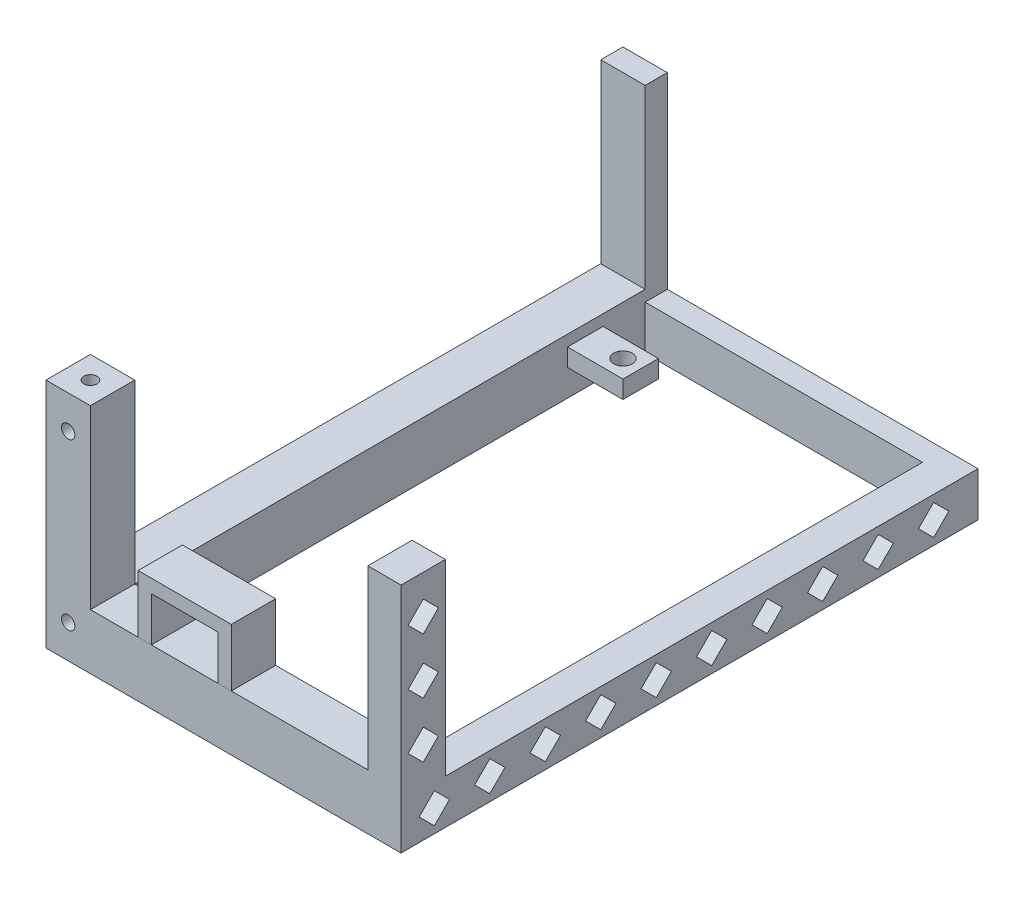
from build123d import *

# Parameters (mm, degrees)
SKETCH1_W           = 80
SKETCH1_H           = 130
BOSS_EXTRUDE1_DEPTH = 10
BOSS_EXTRUDE2_DEPTH = 42.3
CUT_EXTRUDE1_DEPTH  = 5.25
SKETCH4_R           = 2.1
CUT_EXTRUDE2_DEPTH  = 11
CUT_EXTRUDE3_DEPTH  = 11
SKETCH7_W           = 115
SKETCH7_H           = 39.8
CUT_EXTRUDE4_DEPTH  = 11
SKETCH8_W           = 62.5
SKETCH8_H           = 39.8
CUT_EXTRUDE5_DEPTH  = 10
SKETCH9_R           = 1.5
CUT_EXTRUDE6_DEPTH  = 4
SKETCH10_R          = 1.5
CUT_EXTRUDE7_DEPTH  = 4
SKETCH11_W          = 12.5
SKETCH11_H          = 8
CUT_EXTRUDE8_DEPTH  = 6
BOSS_EXTRUDE3_DEPTH = 10
SKETCH14_R          = 1.5
CUT_EXTRUDE9_DEPTH  = 4


with BuildPart() as part:
    # Sketch1 → Boss-Extrude1 (new body)
    with BuildSketch(Plane(origin=(0, 0, 0), x_dir=(1, 0, 0), z_dir=(0, 1, 0))):
        with Locations((-5, 0)):
            Rectangle(SKETCH1_W, SKETCH1_H)
    extrude(amount=BOSS_EXTRUDE1_DEPTH)

    # Sketch2 → Boss-Extrude2 (add)
    with BuildSketch(Plane(origin=(0, 10, 0), x_dir=(1, 0, 0), z_dir=(0, 1, 0))):
        Polygon((35, -65), (-45, -65), (-45, 65), (-35, 65), (-35, -55), (35, -55), align=None)
    extrude(amount=BOSS_EXTRUDE2_DEPTH)

    # Sketch3 → Cut-Extrude1 (cut)
    with BuildSketch(Plane(origin=(35, 0, 0), x_dir=(0, 0, -1), z_dir=(1, 0, 0))):
        Polygon((20.925, 5), (17.5, 8.425), (14.075, 5), (17.5, 1.575), align=None)
        Polygon((33.425, 5), (30, 8.425), (26.575, 5), (30, 1.575), align=None)
        Polygon((5, 8.425), (1.575, 5), (5, 1.575), (8.425, 5), align=None)
        Polygon((-4.075, 5), (-7.5, 8.425), (-10.925, 5), (-7.5, 1.575), align=None)
        Polygon((-16.575, 5), (-20, 8.425), (-23.425, 5), (-20, 1.575), align=None)
        Polygon((-29.075, 5), (-32.5, 8.425), (-35.925, 5), (-32.5, 1.575), align=None)
        Polygon((-41.575, 5), (-45, 8.425), (-48.425, 5), (-45, 1.575), align=None)
        Polygon((-54.075, 5), (-57.5, 8.425), (-60.925, 5), (-57.5, 1.575), align=None)
        Polygon((-63.425, 31.15), (-60, 34.575), (-56.575, 31.15), (-60, 27.725), align=None)
        Polygon((-60, 40.225), (-63.425, 43.65), (-60, 47.075), (-56.575, 43.65), align=None)
        Polygon((-60, 15.225), (-63.425, 18.65), (-60, 22.075), (-56.575, 18.65), align=None)
        Polygon((45.925, 5), (42.5, 8.425), (39.075, 5), (42.5, 1.575), align=None)
        Polygon((58.425, 5), (55, 8.425), (51.575, 5), (55, 1.575), align=None)
    extrude(amount=-CUT_EXTRUDE1_DEPTH, mode=Mode.SUBTRACT)

    # Sketch4 → Cut-Extrude2 (cut, through all)
    with BuildSketch(Plane(origin=(0, 10, 0), x_dir=(1, 0, 0), z_dir=(0, 1, 0))):
        with Locations((-26.5, 46.5)):
            Circle(SKETCH4_R)
    extrude(amount=-CUT_EXTRUDE2_DEPTH, mode=Mode.SUBTRACT)

    # Sketch5 → Cut-Extrude3 (cut, through all)
    with BuildSketch(Plane(origin=(0, 10, 0), x_dir=(1, 0, 0), z_dir=(0, 1, 0))):
        Polygon((-35, -55), (-35, 42.5), (-22.5, 42.5), (-22.5, 50.5), (-35, 50.5), (-35, 60), (27.5, 60), (27.5, -55), align=None)
    extrude(amount=-CUT_EXTRUDE3_DEPTH, mode=Mode.SUBTRACT)

    # Sketch7 → Cut-Extrude4 (cut, through all)
    with BuildSketch(Plane(origin=(-35, 0, 0), x_dir=(0, 0, -1), z_dir=(1, 0, 0))):
        with Locations((2.5, 32.4)):
            Rectangle(SKETCH7_W, SKETCH7_H)
    extrude(amount=-CUT_EXTRUDE4_DEPTH, mode=Mode.SUBTRACT)

    # Sketch8 → Cut-Extrude5 (cut)
    with BuildSketch(Plane(origin=(0, 0, 55), x_dir=(-1, 0, 0), z_dir=(0, 0, -1))):
        with Locations((3.75, 32.4)):
            Rectangle(SKETCH8_W, SKETCH8_H)
    extrude(amount=-CUT_EXTRUDE5_DEPTH, mode=Mode.SUBTRACT)

    # Sketch9 → Cut-Extrude6 (cut)
    with BuildSketch(Plane(origin=(0, 52.3, 0), x_dir=(1, 0, 0), z_dir=(0, 1, 0))):
        with Locations((-40, -60)):
            Circle(SKETCH9_R)
    extrude(amount=-CUT_EXTRUDE6_DEPTH, mode=Mode.SUBTRACT)

    # Sketch10 → Cut-Extrude7 (cut)
    with BuildSketch(Plane.XZ):
        with Locations((-40, 60)):
            Circle(SKETCH10_R)
    extrude(amount=-CUT_EXTRUDE7_DEPTH, mode=Mode.SUBTRACT)

    # Sketch11 → Cut-Extrude8 (cut)
    with BuildSketch(Plane.XZ):
        with Locations((-28.75, -46.5)):
            Rectangle(SKETCH11_W, SKETCH11_H)
    extrude(amount=-CUT_EXTRUDE8_DEPTH, mode=Mode.SUBTRACT)

    # Sketch14 → Cut-Extrude9 (cut)
    with BuildSketch(Plane.XY.offset(65)):
        with Locations((-40, 44.8)):
            Circle(SKETCH14_R)
        with Locations((-40, 7.5)):
            Circle(SKETCH14_R)
    extrude(amount=-CUT_EXTRUDE9_DEPTH, mode=Mode.SUBTRACT)


with BuildPart() as body_2:
    # Sketch13 → Boss-Extrude3 (new body)
    with BuildSketch(Plane.XY.offset(65)):
        Polygon((-24.25, 12.5), (-21.25, 12.5), (-21.25, 22.5), (-6.25, 22.5), (-6.25, 12.5), (-3.25, 12.5), (-3.25, 25.5), (-24.25, 25.5), align=None)
    extrude(amount=-BOSS_EXTRUDE3_DEPTH)


solid = Compound([part.part, body_2.part])
